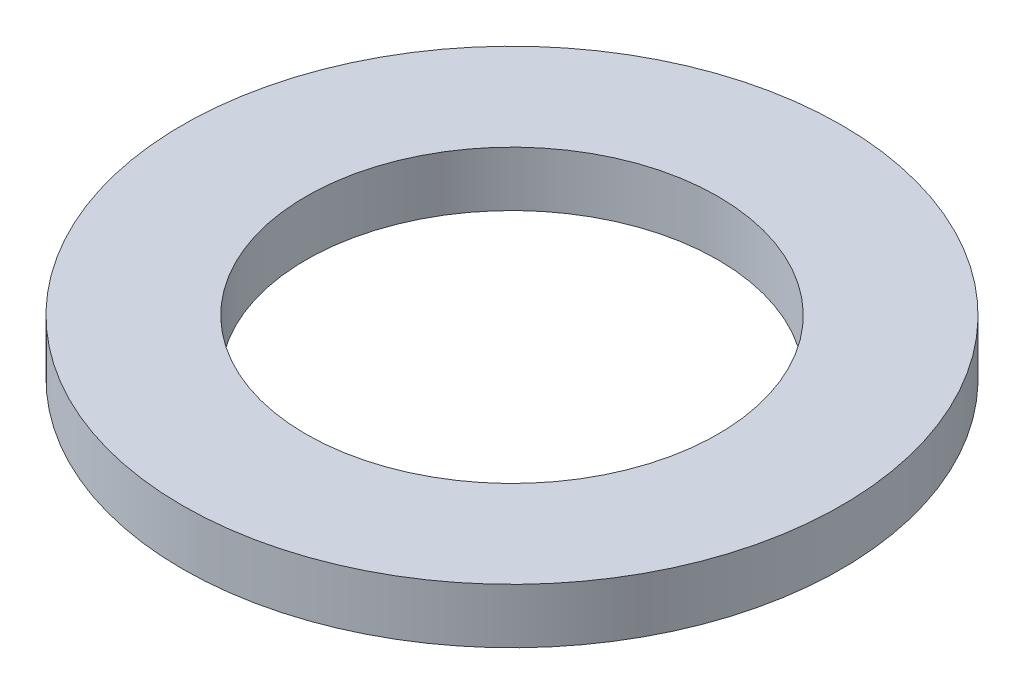
from build123d import *

# Parameters (mm, degrees)
SKETCH1_R           = 6
BOSS_EXTRUDE1_DEPTH = 1
CUT_EXTRUDE1_REACH  = 3
SKETCH2_R           = 3.75


with BuildPart() as part:
    # Sketch1 → Boss-Extrude1 (new body)
    with BuildSketch(Plane(origin=(0, 0, 0), x_dir=(1, 0, 0), z_dir=(0, 1, 0))):
        Circle(SKETCH1_R)
    extrude(amount=BOSS_EXTRUDE1_DEPTH)

    # Sketch2 → Cut-Extrude1 (cut, up to next)
    with BuildSketch(Plane(origin=(0, 1, 0), x_dir=(1, 0, 0), z_dir=(0, 1, 0)), mode=Mode.PRIVATE) as cut_extrude1_sk1:
        Circle(SKETCH2_R)
    cut_extrude1_tool1 = extrude(cut_extrude1_sk1.sketch, amount=-CUT_EXTRUDE1_REACH, mode=Mode.PRIVATE) & part.part
    add(cut_extrude1_tool1.solids().sort_by_distance((0, 1, 0))[0], mode=Mode.SUBTRACT)


solid = part.part
